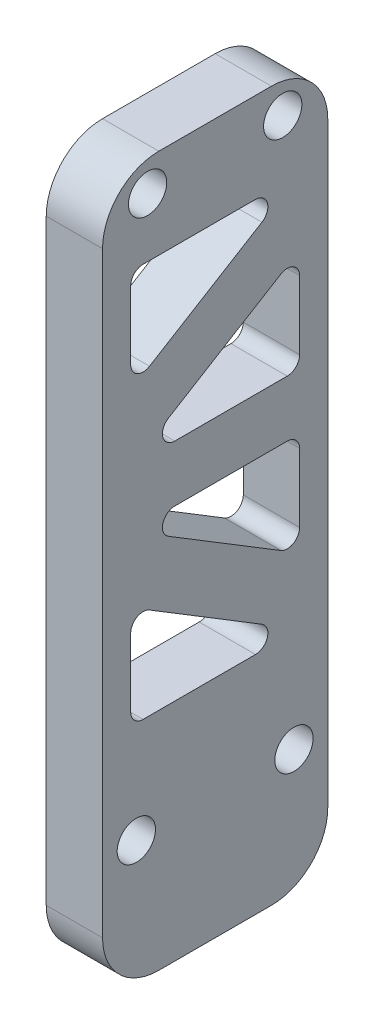
from build123d import *

# Parameters (mm, degrees)
SKETCH_1_W          = 20
SKETCH_1_H          = 63
EXTRUDE_1_DEPTH     = 5
HOLE_WIZARD_M3_1_D  = 3.4
FILLET_1_R          = 5
CUT_EXTRUDE_1_DEPTH = 10
FILLET_2_R          = 1.1


with BuildPart() as part:
    # 草图1 → 凸台-拉伸1 (new body)
    with BuildSketch(Plane(origin=(0, 0, 0), x_dir=(0, 0, -1), z_dir=(1, 0, 0))):
        with Locations((10, 31.5)):
            Rectangle(SKETCH_1_W, SKETCH_1_H)
    extrude(amount=EXTRUDE_1_DEPTH)

    # M3 间隙孔1 (through all)
    with Locations(Plane(origin=(5, 0, 0), x_dir=(0, 0, -1), z_dir=(1, 0, 0))):
        with Locations((3, 11), (17, 11), (16, 60.25), (4, 60.25)):
            Hole(HOLE_WIZARD_M3_1_D / 2)

    # 圆角1
    fillet_1_edges = [part.edges().sort_by_distance(p)[0] for p in [
        (2.5, 63, 0),
        (2.5, 63, -20),
        (2.5, 0, -20),
        (2.5, 0, 0),
    ]]
    fillet(fillet_1_edges, radius=FILLET_1_R)

    # 草图4 → 切除-拉伸1 (cut)
    with BuildSketch(Plane(origin=(5, 0, 0), x_dir=(0, 0, -1), z_dir=(1, 0, 0))):
        Polygon((2.5, 45.855823048), (17.5, 55), (2.5, 55), align=None)
        Polygon((17.5, 40), (17.5, 49.144176952), (2.5, 40), align=None)
        Polygon((17.5, 25.855823048), (17.5, 35), (2.5, 35), align=None)
        Polygon((17.5, 20), (2.5, 29.144176952), (2.5, 20), align=None)
    extrude(amount=-CUT_EXTRUDE_1_DEPTH, mode=Mode.SUBTRACT)

    # 圆角2
    fillet_2_edges = [part.edges().sort_by_distance(p)[0] for p in [
        (2.5, 55, -17.5),
        (2.5, 45.855823048, -2.5),
        (2.5, 55, -2.5),
        (2.5, 40, -2.5),
        (2.5, 49.144176952, -17.5),
        (2.5, 40, -17.5),
        (2.5, 25.855823048, -17.5),
        (2.5, 35, -2.5),
        (2.5, 35, -17.5),
        (2.5, 20, -17.5),
        (2.5, 20, -2.5),
        (2.5, 29.144176952, -2.5),
    ]]
    fillet(fillet_2_edges, radius=FILLET_2_R)


solid = part.part
